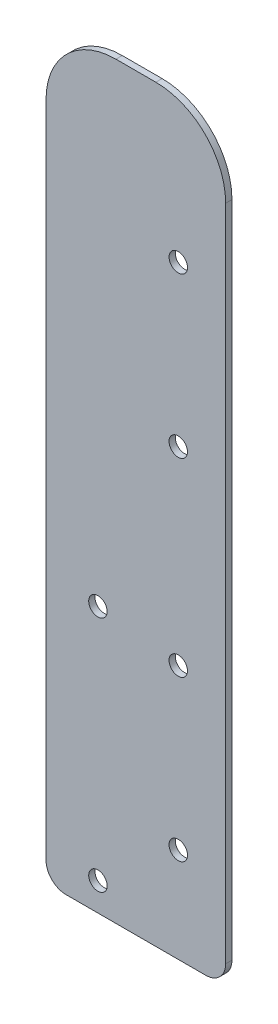
from build123d import *

# Parameters (mm, degrees)
SKETCH1_R           = 2.3495
BOSS_EXTRUDE2_DEPTH = 1.6002


with BuildPart() as part:
    # Sketch1 → Boss-Extrude2 (new body)
    with BuildSketch(Plane.XY):
        with BuildLine():
            Line((45.72, 5.08), (45.72, 172.72))
            ThreePointArc((45.72, 172.72), (40.512358569, 185.292358569), (27.94, 190.5))
            Line((27.94, 190.5), (17.78, 190.5))
            ThreePointArc((17.78, 190.5), (5.207641431, 185.292358569), (0, 172.72))
            Line((0, 172.72), (0, 4.761637225))
            ThreePointArc((0, 4.761637225), (1.592291129, 1.377049629), (5.070014314, 0))
            Line((5.070014314, 0), (33.655, 0))
            Line((33.655, 0), (40.64, 0))
            ThreePointArc((40.64, 0), (44.232102448, 1.487897552), (45.72, 5.08))
        make_face()
        with Locations((33.655, 24.13)):
            Circle(SKETCH1_R, mode=Mode.SUBTRACT)
        with Locations((33.655, 64.77)):
            Circle(SKETCH1_R, mode=Mode.SUBTRACT)
        with Locations((33.655, 113.03)):
            Circle(SKETCH1_R, mode=Mode.SUBTRACT)
        with Locations((33.655, 153.67)):
            Circle(SKETCH1_R, mode=Mode.SUBTRACT)
        with Locations((13.208, 7.15102725)):
            Circle(SKETCH1_R, mode=Mode.SUBTRACT)
        with Locations((13.208, 67.603137295)):
            Circle(SKETCH1_R, mode=Mode.SUBTRACT)
    extrude(amount=BOSS_EXTRUDE2_DEPTH)


solid = part.part
